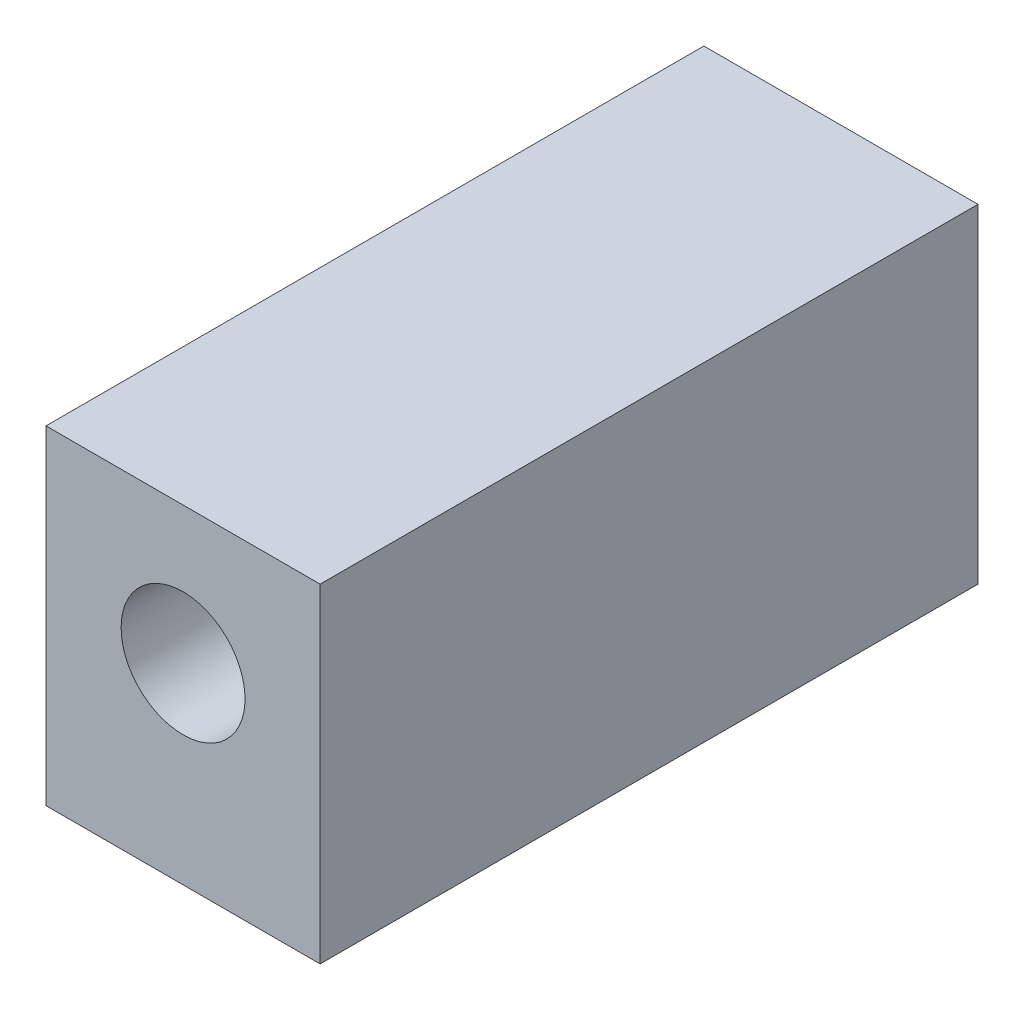
from build123d import *

# Parameters (mm, degrees)
SKETCH_1_W          = 25
SKETCH_1_H          = 30
EXTRUDE_1_DEPTH     = 60
SKETCH_2_R          = 9.6
CUT_EXTRUDE_1_DEPTH = 47.5
SKETCH_3_R          = 5.65
CUT_EXTRUDE_2_DEPTH = 13.5


with BuildPart() as part:
    # ｽｹｯﾁ1 → ﾎﾞｽ - 押し出し1 (new body)
    with BuildSketch(Plane.XY):
        with Locations((1.917887822, -3.131578947)):
            Rectangle(SKETCH_1_W, SKETCH_1_H)
    extrude(amount=EXTRUDE_1_DEPTH)

    # ｽｹｯﾁ2 → ｶｯﾄ - 押し出し1 (cut)
    with BuildSketch(Plane(origin=(0, 0, 0), x_dir=(-1, 0, 0), z_dir=(0, 0, -1))):
        with Locations((-1.917887822, -0.631578947)):
            Circle(SKETCH_2_R)
    extrude(amount=-CUT_EXTRUDE_1_DEPTH, mode=Mode.SUBTRACT)

    # ｽｹｯﾁ3 → ｶｯﾄ - 押し出し2 (cut, through all)
    with BuildSketch(Plane(origin=(0, 0, 47.5), x_dir=(-1, 0, 0), z_dir=(0, 0, -1))):
        with Locations((-1.917887822, -0.631578947)):
            Circle(SKETCH_3_R)
    extrude(amount=-CUT_EXTRUDE_2_DEPTH, mode=Mode.SUBTRACT)


solid = part.part
